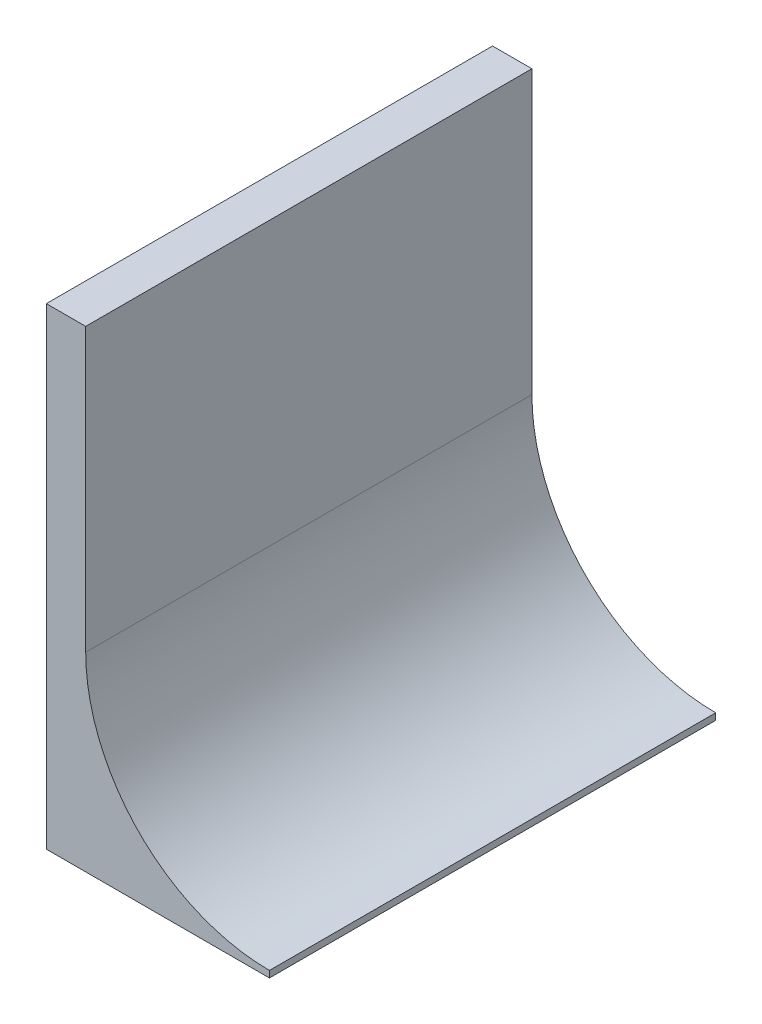
from build123d import *

# Parameters (mm, degrees)
SKETCH1_W           = 215.9
SKETCH1_H           = 279.4
BOSS_EXTRUDE1_DEPTH = 63.5
CUT_EXTRUDE2_DEPTH  = 216.9


with BuildPart() as part:
    # Sketch1 → Boss-Extrude1 (new body, symmetric)
    with BuildSketch(Plane(origin=(-316.495998982, -92.239904424, -225.371199256), x_dir=(0, 0, -1), z_dir=(1, 0, 0))):
        with Locations((-225.371199256, 92.239904424)):
            Rectangle(SKETCH1_W, SKETCH1_H)
    extrude(amount=BOSS_EXTRUDE1_DEPTH, both=True)

    # Sketch2 → Cut-Extrude2 (cut, through all)
    with BuildSketch(Plane.XY.offset(107.95)):
        with BuildLine():
            Line((-272.045998982, -139.7), (-252.995998982, -139.7))
            Line((-252.995998982, -139.7), (-252.995998982, 139.7))
            Line((-252.995998982, 139.7), (-379.995998982, 139.7))
            Line((-379.995998982, 139.7), (-379.995998982, 88.9))
            Line((-379.995998982, 88.9), (-360.945998982, 88.9))
            Line((-360.945998982, 88.9), (-360.945998982, -47.625))
            ThreePointArc((-360.945998982, -47.625), (-334.90779183, -110.486792847), (-272.045998982, -136.525))
            Line((-272.045998982, -136.525), (-272.045998982, -139.7))
        make_face()
    extrude(amount=-CUT_EXTRUDE2_DEPTH, mode=Mode.SUBTRACT)


solid = part.part
